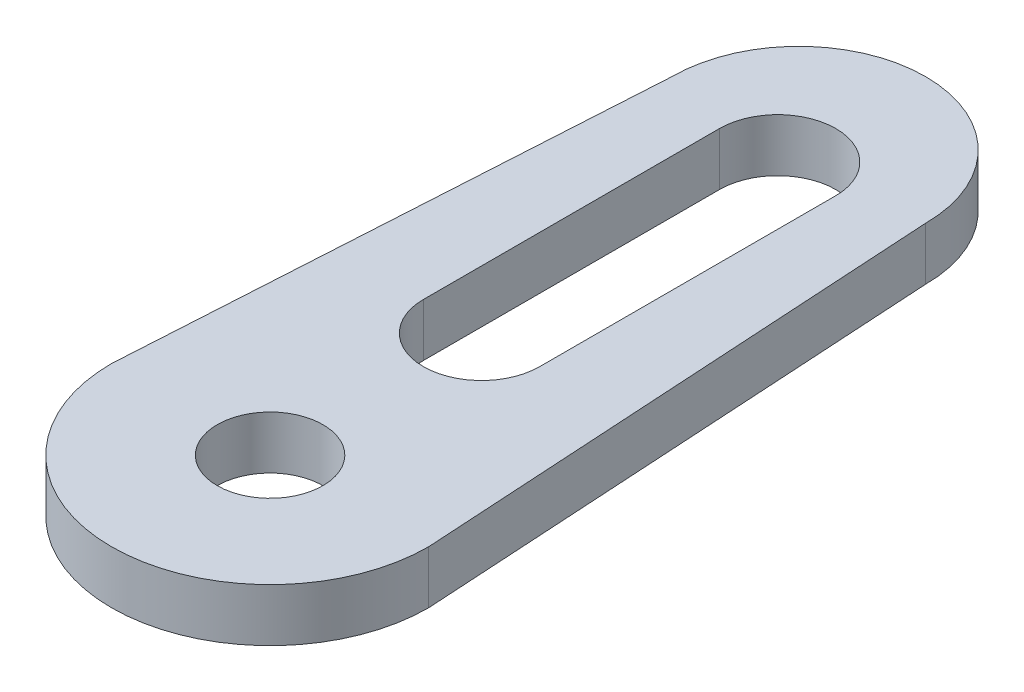
from build123d import *

# Parameters (mm, degrees)
BOSS_EXTRUDE1_DEPTH = 2.5
SKETCH2_R           = 2.5
CUT_EXTRUDE1_DEPTH  = 3.5


with BuildPart() as part:
    # Sketch1 → Boss-Extrude1 (new body)
    with BuildSketch(Plane(origin=(0, 0, 0), x_dir=(1, 0, 0), z_dir=(0, 1, 0))):
        with BuildLine():
            Line((-6, 25), (-7.5, 0))
            ThreePointArc((-7.5, 0), (0, -7.5), (7.5, 0))
            Line((7.5, 0), (6, 25))
            ThreePointArc((6, 25), (0, 31), (-6, 25))
        make_face()
    extrude(amount=BOSS_EXTRUDE1_DEPTH)

    # Sketch2 → Cut-Extrude1 (cut, through all)
    with BuildSketch(Plane(origin=(0, 2.5, 0), x_dir=(1, 0, 0), z_dir=(0, 1, 0))):
        Circle(SKETCH2_R)
        with BuildLine():
            Line((2.75, 24), (2.75, 10))
            ThreePointArc((2.75, 10), (0, 7.25), (-2.75, 10))
            Line((-2.75, 10), (-2.75, 24))
            ThreePointArc((-2.75, 24), (0, 26.75), (2.75, 24))
        make_face()
    extrude(amount=-CUT_EXTRUDE1_DEPTH, mode=Mode.SUBTRACT)


solid = part.part
